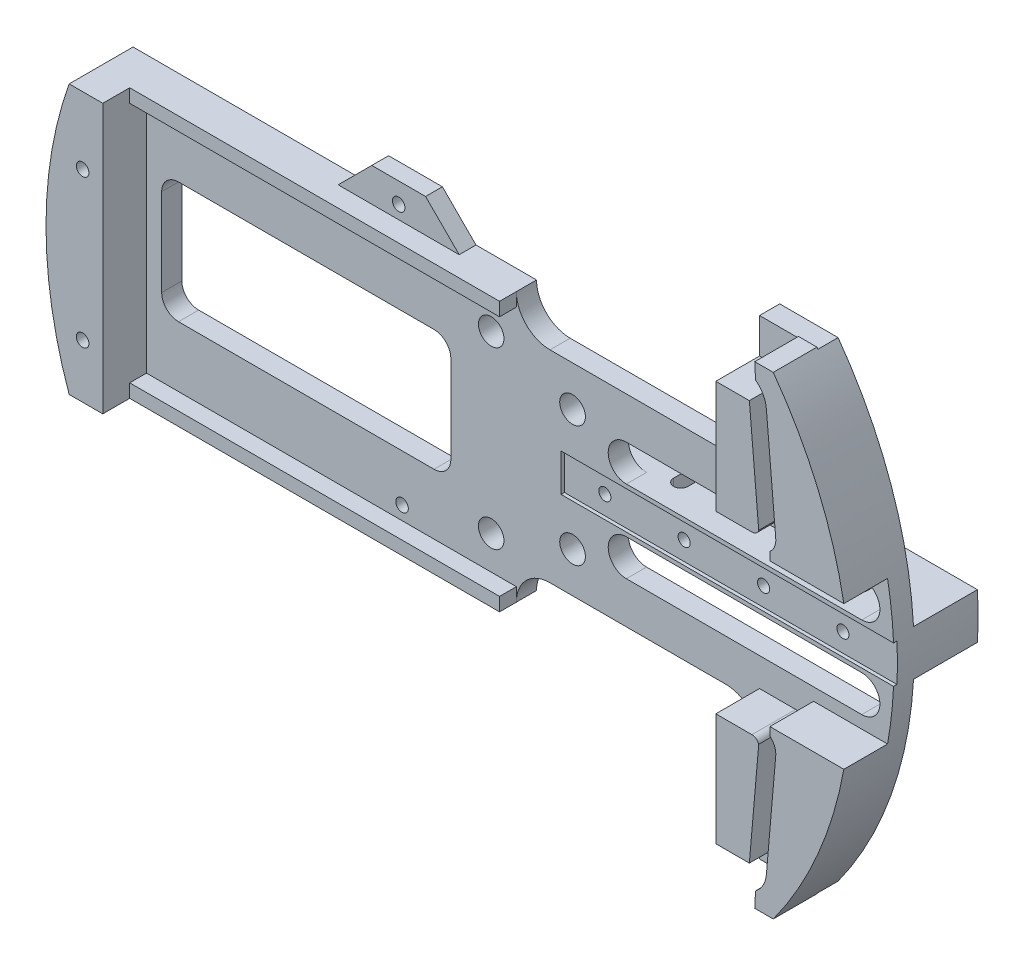
from build123d import *

# Parameters (mm, degrees)
BOSS_EXTRUDE1_DEPTH     = 3.81
BOSS_EXTRUDE2_DEPTH     = 8.255
SKETCH3_W               = 63.5
SKETCH3_H               = 7.1
CUT_EXTRUDE1_DEPTH      = 0.635
CUT_EXTRUDE4_DEPTH      = 4.81
CUT_EXTRUDE5_DEPTH      = 4.81
SKETCH12_R              = 2.4257
CUT_EXTRUDE6_DEPTH      = 4.81
BOSS_EXTRUDE3_DEPTH     = 12.065
SKETCH4_R               = 1.143
CUT_EXTRUDE2_DEPTH      = 11.43
CUT_EXTRUDE7_DEPTH      = 50.016
CUT_EXTRUDE8_DEPTH      = 41.392
CUT_EXTRUDE8_DEPTH_BACK = 50.016
SKETCH17_R              = 2.413
CUT_EXTRUDE9_DEPTH      = 16.875
BOSS_EXTRUDE5_DEPTH     = 8.255
SKETCH20_W              = 69.85
SKETCH20_H              = 3.175
BOSS_EXTRUDE6_DEPTH     = 2.54
BOSS_EXTRUDE7_DEPTH     = 3.175
SKETCH22_R              = 1.18745
CUT_EXTRUDE10_DEPTH     = 13.065


with BuildPart() as part:
    # Sketch1 → Boss-Extrude1 (new body)
    with BuildSketch(Plane.XY):
        with BuildLine():
            Line((10.977415053, 19.05), (44.196, 19.05))
            ThreePointArc((44.196, 19.05), (48.686128061, 20.909871939), (50.546, 25.4))
            Line((50.546, 25.4), (50.546, 44.45))
            Line((50.546, 44.45), (61.579155694, 44.45))
            ThreePointArc((61.579155694, 44.45), (75.946, 0), (61.579155694, -44.45))
            Line((61.579155694, -44.45), (50.546, -44.45))
            Line((50.546, -44.45), (50.546, -25.4))
            ThreePointArc((50.546, -25.4), (48.686128061, -20.909871939), (44.196, -19.05))
            Line((44.196, -19.05), (10.977415053, -19.05))
            ThreePointArc((10.977415053, -19.05), (6.487286992, -20.909871939), (4.627415053, -25.4))
            Line((4.627415053, -25.4), (-71.572584947, -25.4))
            ThreePointArc((-71.572584947, -25.4), (-75.946, 0), (-71.572584947, 25.4))
            Line((-71.572584947, 25.4), (4.627415053, 25.4))
            ThreePointArc((4.627415053, 25.4), (6.487286992, 20.909871939), (10.977415053, 19.05))
        make_face()
    extrude(amount=BOSS_EXTRUDE1_DEPTH)

    # Sketch2 → Boss-Extrude2 (add)
    with BuildSketch(Plane.XY.offset(3.81)):
        with BuildLine():
            Line((61.865268471, 17.78), (60.095110466, 38.1))
            ThreePointArc((60.095110466, 38.1), (59.464196764, 40.158289632), (58.047089349, 41.778911391))
            Line((58.047089349, 41.778911391), (57.900800643, 44.704))
            Line((57.900800643, 44.704), (61.395010384, 44.704))
            ThreePointArc((61.395010384, 44.704), (69.822038137, 29.877715884), (74.728381149, 13.544887112))
            Line((74.728381149, 13.544887112), (60.759450402, 13.544887112))
            Line((60.759450402, 13.544887112), (60.759450402, 15.094127876))
            ThreePointArc((60.759450402, 15.094127876), (61.639191639, 16.302501703), (61.865268471, 17.78))
        make_face()
        with BuildLine():
            Line((58.651639318, 17.500047669), (56.881481313, 37.820047669))
            Line((56.881481313, 37.820047669), (50.546, 37.820047669))
            Line((50.546, 37.820047669), (50.546, 16.566735288))
            Line((50.546, 16.566735288), (57.366094516, 16.566735288))
            ThreePointArc((57.366094516, 16.566735288), (58.160401987, 16.824667019), (58.651639318, 17.500047669))
        make_face()
        with BuildLine():
            Line((60.759450402, -13.544887112), (74.728381149, -13.544887112))
            ThreePointArc((74.728381149, -13.544887112), (69.822038137, -29.877715884), (61.395010384, -44.704))
            Line((61.395010384, -44.704), (57.900800643, -44.704))
            Line((57.900800643, -44.704), (58.047089349, -41.778911391))
            ThreePointArc((58.047089349, -41.778911391), (59.464196764, -40.158289632), (60.095110466, -38.1))
            Line((60.095110466, -38.1), (61.865268471, -17.78))
            ThreePointArc((61.865268471, -17.78), (61.639191639, -16.302501703), (60.759450402, -15.094127876))
            Line((60.759450402, -15.094127876), (60.759450402, -13.544887112))
        make_face()
        with BuildLine():
            Line((50.546, -16.566735288), (57.366094516, -16.566735288))
            ThreePointArc((57.366094516, -16.566735288), (58.160401987, -16.824667019), (58.651639318, -17.500047669))
            Line((58.651639318, -17.500047669), (56.881481313, -37.820047669))
            Line((56.881481313, -37.820047669), (50.546, -37.820047669))
            Line((50.546, -37.820047669), (50.546, -16.566735288))
        make_face()
    extrude(amount=BOSS_EXTRUDE2_DEPTH)

    # Sketch3 → Cut-Extrude1 (cut)
    with BuildSketch(Plane.XY.offset(3.81)):
        with Locations((44.831, 0)):
            Rectangle(SKETCH3_W, SKETCH3_H)
    extrude(amount=-CUT_EXTRUDE1_DEPTH, mode=Mode.SUBTRACT)

    # Sketch9 → Cut-Extrude4 (cut, through all)
    with BuildSketch(Plane.XY.offset(3.81)):
        with BuildLine():
            Line((69.85, 11.17), (25.4, 11.17))
            ThreePointArc((25.4, 11.17), (21.971, 7.741), (25.4, 4.312))
            Line((25.4, 4.312), (69.85, 4.312))
            ThreePointArc((69.85, 4.312), (73.279, 7.741), (69.85, 11.17))
        make_face()
        with BuildLine():
            Line((69.85, -4.312), (25.4, -4.312))
            ThreePointArc((25.4, -4.312), (21.971, -7.741), (25.4, -11.17))
            Line((25.4, -11.17), (69.85, -11.17))
            ThreePointArc((69.85, -11.17), (73.279, -7.741), (69.85, -4.312))
        make_face()
    extrude(amount=-CUT_EXTRUDE4_DEPTH, mode=Mode.SUBTRACT)

    # Sketch10 → Cut-Extrude5 (cut, through all)
    with BuildSketch(Plane.XY.offset(3.81)):
        with BuildLine():
            Line((-10.922, 11.43), (-59.182, 11.43))
            ThreePointArc((-59.182, 11.43), (-61.42706403, 10.50006403), (-62.357, 8.255))
            Line((-62.357, 8.255), (-62.357, -8.255))
            ThreePointArc((-62.357, -8.255), (-61.42706403, -10.50006403), (-59.182, -11.43))
            Line((-59.182, -11.43), (-10.922, -11.43))
            ThreePointArc((-10.922, -11.43), (-8.67693597, -10.50006403), (-7.747, -8.255))
            Line((-7.747, -8.255), (-7.747, 8.255))
            ThreePointArc((-7.747, 8.255), (-8.67693597, 10.50006403), (-10.922, 11.43))
        make_face()
    extrude(amount=-CUT_EXTRUDE5_DEPTH, mode=Mode.SUBTRACT)

    # Sketch12 → Cut-Extrude6 (cut, through all)
    with BuildSketch(Plane.XY.offset(3.81)):
        with Locations((15.24, 11.43)):
            Circle(SKETCH12_R)
        with Locations((15.24, -11.43)):
            Circle(SKETCH12_R)
    extrude(amount=-CUT_EXTRUDE6_DEPTH, mode=Mode.SUBTRACT)

    # Sketch14 → Boss-Extrude3 (add)
    with BuildSketch(Plane(origin=(0, 0, 0), x_dir=(-1, 0, 0), z_dir=(0, 0, -1))):
        with BuildLine():
            Line((-75.823489579, 4.312), (7.747, 4.312))
            Line((7.747, 4.312), (7.747, -4.312))
            Line((7.747, -4.312), (-75.823489579, -4.312))
            ThreePointArc((-75.823489579, -4.312), (-75.946, 0), (-75.823489579, 4.312))
        make_face()
    extrude(amount=BOSS_EXTRUDE3_DEPTH)

    # Sketch4 → Cut-Extrude2 (cut)
    with BuildSketch(Plane.XY.offset(3.175)):
        with Locations((20.701, 0)):
            Circle(SKETCH4_R)
        with Locations((35.687, 0)):
            Circle(SKETCH4_R)
        with Locations((50.673, 0)):
            Circle(SKETCH4_R)
        with Locations((65.659, 0)):
            Circle(SKETCH4_R)
    extrude(amount=-CUT_EXTRUDE2_DEPTH, mode=Mode.SUBTRACT)

    # Sketch15 → Cut-Extrude7 (cut, through all)
    with BuildSketch(Plane(origin=(0, 4.312, 0), x_dir=(1, 0, 0), z_dir=(0, 1, 0))):
        with BuildLine():
            Line((28.8925, 1.615666853), (28.8925, 5.933666853))
            ThreePointArc((28.8925, 5.933666853), (30.2514, 7.292566853), (31.6103, 5.933666853))
            Line((31.6103, 5.933666853), (31.6103, 1.615666853))
            ThreePointArc((31.6103, 1.615666853), (30.2514, 0.256766853), (28.8925, 1.615666853))
        make_face()
        with BuildLine():
            Line((41.1099, 1.615666853), (41.1099, 5.933666853))
            ThreePointArc((41.1099, 5.933666853), (39.751, 7.292566853), (38.3921, 5.933666853))
            Line((38.3921, 5.933666853), (38.3921, 1.615666853))
            ThreePointArc((38.3921, 1.615666853), (39.751, 0.256766853), (41.1099, 1.615666853))
        make_face()
        with BuildLine():
            Line((65.5955, 1.615666853), (65.5955, 5.933666853))
            ThreePointArc((65.5955, 5.933666853), (64.2366, 7.292566853), (62.8777, 5.933666853))
            Line((62.8777, 5.933666853), (62.8777, 1.615666853))
            ThreePointArc((62.8777, 1.615666853), (64.2366, 0.256766853), (65.5955, 1.615666853))
        make_face()
        with BuildLine():
            Line((56.0959, 1.615666853), (56.0959, 5.933666853))
            ThreePointArc((56.0959, 5.933666853), (54.737, 7.292566853), (53.3781, 5.933666853))
            Line((53.3781, 5.933666853), (53.3781, 1.615666853))
            ThreePointArc((53.3781, 1.615666853), (54.737, 0.256766853), (56.0959, 1.615666853))
        make_face()
    extrude(amount=-CUT_EXTRUDE7_DEPTH, mode=Mode.SUBTRACT)

    # Sketch16 → Cut-Extrude8 (cut, two sides)
    with BuildSketch(Plane.XZ.offset(4.312)) as cut_extrude8_sk:
        with BuildLine():
            Line((4.627415053, 0), (-7.747, 0))
            Line((-7.747, 0), (-7.747, -12.065))
            Line((-7.747, -12.065), (0, -12.065))
            Line((0, -12.065), (22.547469063, -12.065))
            ThreePointArc((22.547469063, -12.065), (14.291875083, -4.986210911), (4.627415053, 0))
        make_face()
    extrude(amount=CUT_EXTRUDE8_DEPTH, mode=Mode.SUBTRACT)
    extrude(cut_extrude8_sk.sketch, amount=-CUT_EXTRUDE8_DEPTH_BACK, mode=Mode.SUBTRACT)

    # Sketch17 → Cut-Extrude9 (cut, through all)
    with BuildSketch(Plane.XY.offset(3.81)):
        with Locations((-0.127, 16.51)):
            Circle(SKETCH17_R)
        with Locations((-0.127, -16.51)):
            Circle(SKETCH17_R)
    extrude(amount=-CUT_EXTRUDE9_DEPTH, mode=Mode.SUBTRACT)

    # Sketch19 → Boss-Extrude5 (add)
    with BuildSketch(Plane.XY.offset(3.81)):
        with BuildLine():
            Line((-71.572584947, -25.4), (-65.222584947, -25.4))
            Line((-65.222584947, -25.4), (-65.222584947, 25.4))
            Line((-65.222584947, 25.4), (-71.572584947, 25.4))
            ThreePointArc((-71.572584947, 25.4), (-75.946, 0), (-71.572584947, -25.4))
        make_face()
    extrude(amount=BOSS_EXTRUDE5_DEPTH)

    # Sketch20 → Boss-Extrude6 (add)
    with BuildSketch(Plane.XZ.offset(25.4)):
        with Locations((-30.297584947, 5.3975)):
            Rectangle(SKETCH20_W, SKETCH20_H)
    boss_extrude6 = extrude(amount=-BOSS_EXTRUDE6_DEPTH)

    # Mirror1: Boss-Extrude6 across plane
    add(boss_extrude6.mirror(Plane.ZX))

    # Sketch21 → Boss-Extrude7 (add)
    with BuildSketch(Plane(origin=(0, 0, 0), x_dir=(-1, 0, 0), z_dir=(0, 0, -1))):
        Polygon((6.802584947, 25.4), (13.152584947, 31.75), (23.312584947, 31.75), (29.662584947, 25.4), align=None)
    extrude(amount=-BOSS_EXTRUDE7_DEPTH)

    # Sketch22 → Cut-Extrude10 (cut, through all)
    with BuildSketch(Plane(origin=(0, 0, 0), x_dir=(-1, 0, 0), z_dir=(0, 0, -1))):
        with Locations((18.232584947, 27.94)):
            Circle(SKETCH22_R)
        with Locations((16.962584947, -20.30328658)):
            Circle(SKETCH22_R)
        with Locations((69.032584947, 12.7)):
            Circle(SKETCH22_R)
        with Locations((69.032584947, -15.24)):
            Circle(SKETCH22_R)
    extrude(amount=-CUT_EXTRUDE10_DEPTH, mode=Mode.SUBTRACT)


solid = part.part
